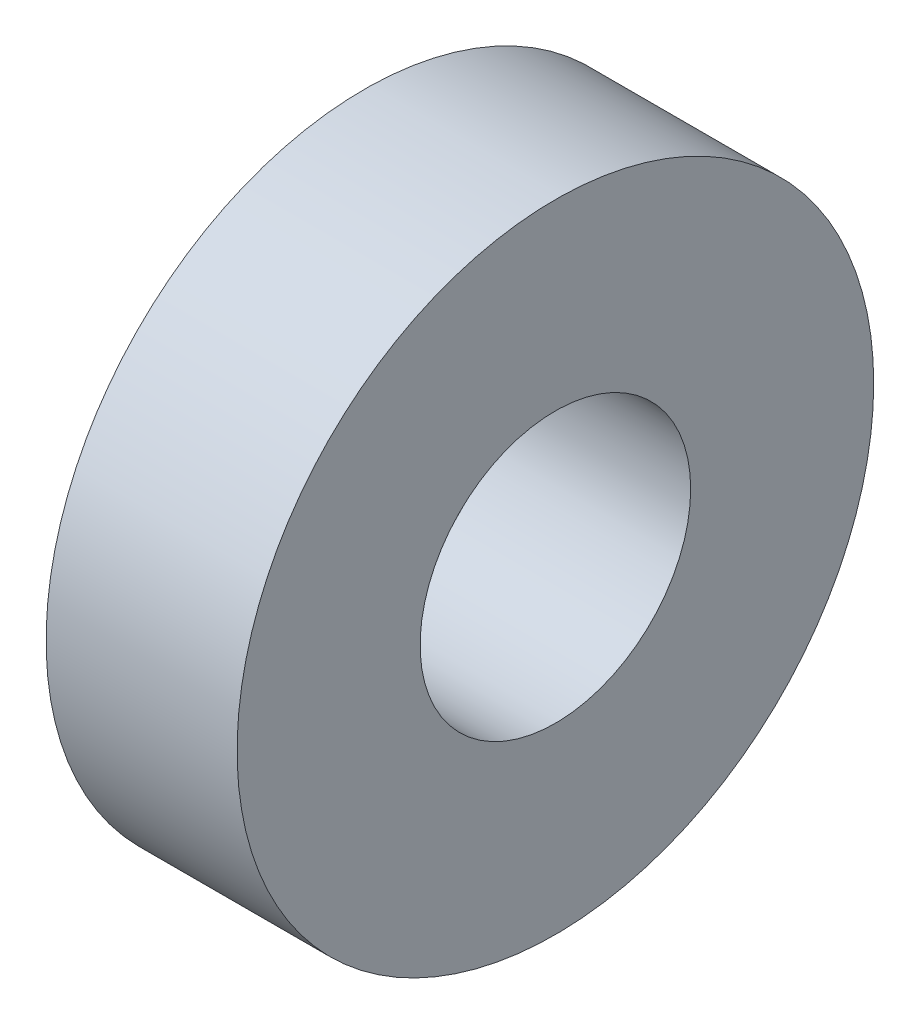
from build123d import *

# Parameters (mm, degrees)
SKETCH1_R      = 20
SKETCH1_R_2    = 8.5
EXTRUDE1_DEPTH = 6


with BuildPart() as part:
    # Sketch1 → Extrude1 (new body, symmetric)
    with BuildSketch(Plane(origin=(0, 0, 0), x_dir=(0, 0, -1), z_dir=(1, 0, 0))):
        Circle(SKETCH1_R)
        Circle(SKETCH1_R_2, mode=Mode.SUBTRACT)
    extrude(amount=EXTRUDE1_DEPTH, both=True)


solid = part.part
